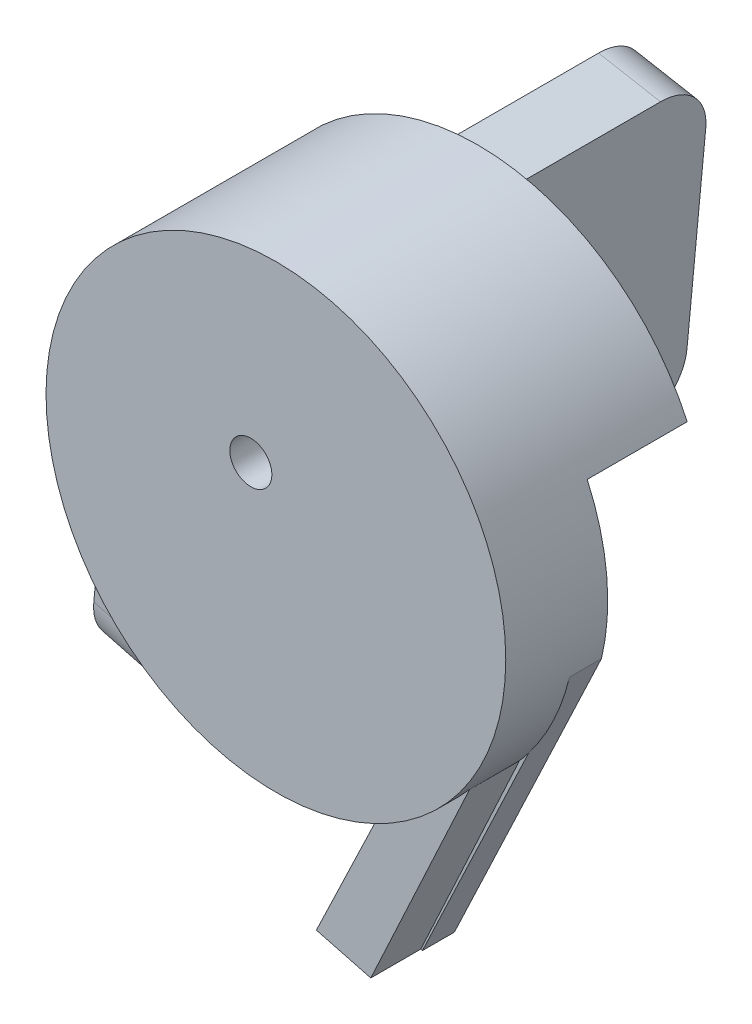
from build123d import *

# Parameters (mm, degrees)
BOSS_EXTRUDE3_DEPTH = 13.2
BOSS_EXTRUDE4_DEPTH = 40
SKETCH3_R           = 23
BOSS_EXTRUDE5_DEPTH = 7
SKETCH4_R           = 2.101716342
CUT_EXTRUDE1_DEPTH  = 10
SKETCH6_W           = 25.714942096
SKETCH6_H           = 53.927163671
CUT_EXTRUDE2_DEPTH  = 10
BOSS_EXTRUDE6_DEPTH = 5
SKETCH11_W          = 0.356169872
SKETCH11_H          = 3.96875
SKETCH11_W_2        = 1.526442308
SKETCH11_H_2        = 0.407051282
CUT_EXTRUDE5_DEPTH  = 5
FILLET5_R           = 5
FILLET6_R           = 5
FILLET7_R           = 5


with BuildPart() as part:
    # Sketch1 → Boss-Extrude3 (new body)
    with BuildSketch(Plane.XY):
        with BuildLine():
            ThreePointArc((-16.733879942, 0.734685024), (4.365374373, 16.171147349), (14.830379862, -7.786034495))
            Line((14.830379862, -7.786034495), (1.98558973, -34.897127547))
            Line((1.98558973, -34.897127547), (7.660402975, -36.381590217))
            Line((7.660402975, -36.381590217), (22.375667903, -5.322545058))
            ThreePointArc((22.375667903, -5.322545058), (3.672252171, 22.704945805), (-22.912677541, 2.002300652))
            Line((-22.912677541, 2.002300652), (-25.690659105, -27.657354808))
            Line((-25.690659105, -27.657354808), (-19.543738844, -29.265314976))
            Line((-19.543738844, -29.265314976), (-16.733879942, 0.734685024))
        make_face()
    extrude(amount=BOSS_EXTRUDE3_DEPTH)

    # Sketch2 → Boss-Extrude4 (add)
    with BuildSketch(Plane(origin=(0, 0, 0), x_dir=(-1, 0, 0), z_dir=(0, 0, -1))):
        Polygon((22.912677541, 2.002300652), (16.720636216, 0.876084213), (19.543738844, -29.265314976), (25.690659105, -27.657354808), align=None)
    extrude(amount=BOSS_EXTRUDE4_DEPTH)

    # Sketch3 → Boss-Extrude5 (add)
    with BuildSketch(Plane.XY.offset(13.2)):
        Circle(SKETCH3_R)
    extrude(amount=BOSS_EXTRUDE5_DEPTH)

    # Sketch4 → Cut-Extrude1 (cut)
    with BuildSketch(Plane.XY.offset(20.2)):
        with Locations((-2.506003926, 4.326655096)):
            Circle(SKETCH4_R)
    extrude(amount=-CUT_EXTRUDE1_DEPTH, mode=Mode.SUBTRACT)

    # Sketch6 → Cut-Extrude2 (cut)
    with BuildSketch(Plane(origin=(0, 0, 0), x_dir=(-1, 0, 0), z_dir=(0, 0, -1))):
        with Locations((-13.331770184, -17.473361846)):
            Rectangle(SKETCH6_W, SKETCH6_H)
    extrude(amount=-CUT_EXTRUDE2_DEPTH, mode=Mode.SUBTRACT)

    # Sketch7 → Boss-Extrude6 (add)
    with BuildSketch(Plane.XY.offset(13.2)):
        with BuildLine():
            Line((8.554145329, -21.350095964), (2.050563603, -34.914123928))
            Line((2.050563603, -34.914123928), (7.494260499, -36.33812935))
            Line((7.494260499, -36.33812935), (17.377955101, -15.066740739))
            ThreePointArc((17.377955101, -15.066740739), (13.34123669, -18.735298332), (8.554145329, -21.350095964))
        make_face()
    extrude(amount=BOSS_EXTRUDE6_DEPTH)

    # Sketch11 → Cut-Extrude5 (cut)
    with BuildSketch(Plane(origin=(-22.899331118, 2.144796313, 0), x_dir=(0, 0, 1), z_dir=(-0.995642368, 0.093253819, 0))):
        with BuildLine():
            Line((-27.490761449, -14.449425234), (-27.796049911, -14.738813255))
            add(Edge.make_bspline(
                [(-27.796049911, -14.738813255), (-27.85129365, -14.68684433), (-27.96046381, -14.584145708), (-28.138445513, -14.450896634), (-28.324141777, -14.336748466), (-28.516583626, -14.243872645), (-28.711005379, -14.169767282), (-28.904826402, -14.117007695), (-29.096058582, -14.083361157), (-29.223248195, -14.079337559), (-29.285921205, -14.077354922)],
                knots=[0, 0, 0, 0, 0.000227393, 0.000449364, 0.000665615, 0.000880379, 0.001089464, 0.001288886, 0.001482323, 0.001670233, 0.001670233, 0.001670233, 0.001670233], degree=3))
            add(Edge.make_bspline(
                [(-29.285921205, -14.077354922), (-29.324378052, -14.077823921), (-29.401192007, -14.078760704), (-29.515290104, -14.090717091), (-29.628191559, -14.107912963), (-29.739683243, -14.132793485), (-29.849981933, -14.164326972), (-29.958704016, -14.203771203), (-30.066052303, -14.249757953), (-30.171015627, -14.302896651), (-30.272774948, -14.36127112), (-30.368883145, -14.42596009), (-30.459952803, -14.494890236), (-30.544272214, -14.569787329), (-30.622326399, -14.649972935), (-30.695973213, -14.733955434), (-30.762622468, -14.824029298), (-30.822824057, -14.918537284), (-30.87652875, -15.015819499), (-30.923936776, -15.114939585), (-30.963734367, -15.215568777), (-30.995222946, -15.317833348), (-31.021201991, -15.420942141), (-31.039478206, -15.525609101), (-31.0497819, -15.631946298), (-31.051564187, -15.703153904), (-31.052460167, -15.738950975)],
                knots=[0, 0, 0, 0, 0.000115322, 0.000230345, 0.000343799, 0.000457798, 0.000572791, 0.000687718, 0.000804532, 0.000922929, 0.001040474, 0.001156236, 0.001270247, 0.001382882, 0.001494196, 0.001605783, 0.001717723, 0.001829979, 0.001941716, 0.002050889, 0.0021594, 0.002266016, 0.002371682, 0.002478206, 0.002584448, 0.002691849, 0.002691849, 0.002691849, 0.002691849], degree=3))
            add(Edge.make_bspline(
                [(-31.052460167, -15.738950975), (-31.051603236, -15.775543777), (-31.049891715, -15.848629457), (-31.038937603, -15.957706665), (-31.018608259, -16.065163862), (-30.991430589, -16.171354156), (-30.957434486, -16.27645941), (-30.915056552, -16.380023953), (-30.864862523, -16.48204395), (-30.806763932, -16.581600176), (-30.743052791, -16.678577176), (-30.671679833, -16.769925919), (-30.595864707, -16.856862836), (-30.512845374, -16.937457676), (-30.425283929, -17.013866201), (-30.330564295, -17.083983266), (-30.230549005, -17.149159466), (-30.12508547, -17.208573376), (-30.015318029, -17.261650912), (-29.902767961, -17.308849437), (-29.787075706, -17.347719757), (-29.668849263, -17.379399571), (-29.548229571, -17.405366873), (-29.424604366, -17.422072453), (-29.298882634, -17.434195092), (-29.214134364, -17.43508145), (-29.171438032, -17.435527998)],
                knots=[0, 0, 0, 0, 0.000109785, 0.00021927, 0.000328423, 0.000437561, 0.000547932, 0.000659544, 0.000772965, 0.000888736, 0.00100516, 0.001120769, 0.001236245, 0.001350932, 0.001467605, 0.001584633, 0.001704151, 0.001825542, 0.001947502, 0.002069752, 0.002191435, 0.00231332, 0.002436812, 0.002561276, 0.002687381, 0.002815419, 0.002815419, 0.002815419, 0.002815419], degree=3))
            add(Edge.make_bspline(
                [(-29.171438032, -17.435527998), (-29.119982227, -17.434452381), (-29.018940395, -17.43234023), (-28.870411125, -17.415897938), (-28.727759429, -17.390218092), (-28.591386145, -17.352610334), (-28.461132881, -17.304640988), (-28.336522135, -17.246815862), (-28.218534986, -17.176917036), (-28.106816744, -17.098025241), (-28.003904579, -17.010128957), (-27.911087849, -16.91528212), (-27.829846982, -16.813945116), (-27.758971117, -16.706714803), (-27.700337197, -16.592703609), (-27.652210099, -16.472470257), (-27.61531967, -16.345960667), (-27.600176082, -16.258544263), (-27.59252427, -16.214374152)],
                knots=[0, 0, 0, 0, 0.000154335, 0.000303061, 0.000447768, 0.000588759, 0.000726848, 0.000863779, 0.001000266, 0.001137694, 0.001273596, 0.001405716, 0.001535217, 0.001662669, 0.001790677, 0.001919117, 0.002050709, 0.002185113, 0.002185113, 0.002185113, 0.002185113], degree=3))
            Line((-27.59252427, -16.214374152), (-28.915440936, -16.214374152))
            Line((-28.915440936, -16.214374152), (-28.915440936, -15.80732287))
            Line((-28.915440936, -15.80732287), (-27.236354398, -15.80732287))
            add(Edge.make_bspline(
                [(-27.236354398, -15.80732287), (-27.238288708, -15.883191183), (-27.242074503, -16.031679177), (-27.26862988, -16.248225824), (-27.311511104, -16.45275444), (-27.370090207, -16.645480423), (-27.445921999, -16.826130658), (-27.538192633, -16.99488856), (-27.648378878, -17.150663903), (-27.772555896, -17.294728398), (-27.91191567, -17.42323563), (-28.062692587, -17.536181649), (-28.225135757, -17.631321222), (-28.399091521, -17.708723937), (-28.583990405, -17.769132842), (-28.780260264, -17.811963112), (-28.987634936, -17.837623874), (-29.129757775, -17.840902492), (-29.202443891, -17.84257928)],
                knots=[0, 0, 0, 0, 0.000227576, 0.000445408, 0.000653412, 0.000853841, 0.001048745, 0.001240174, 0.001429639, 0.00162013, 0.00180972, 0.001997187, 0.002184263, 0.002373234, 0.002567323, 0.002766779, 0.002975044, 0.003193056, 0.003193056, 0.003193056, 0.003193056], degree=3))
            add(Edge.make_bspline(
                [(-29.202443891, -17.84257928), (-29.247245562, -17.841933938), (-29.335608898, -17.840661114), (-29.466113789, -17.831615371), (-29.593020377, -17.817690075), (-29.716310173, -17.79666123), (-29.836436686, -17.770904434), (-29.952799965, -17.737922173), (-30.06584328, -17.699744273), (-30.175741353, -17.656319714), (-30.281496687, -17.606005425), (-30.383580327, -17.550091816), (-30.482556559, -17.488867202), (-30.577751183, -17.421272761), (-30.6696602, -17.347814078), (-30.75769098, -17.26834392), (-30.842336342, -17.18310524), (-30.895359368, -17.122577255), (-30.922076553, -17.092078479)],
                knots=[0, 0, 0, 0, 0.000134396, 0.000265073, 0.000392289, 0.000517239, 0.000640121, 0.000760684, 0.000879852, 0.000997958, 0.001114959, 0.001230945, 0.001346988, 0.001463899, 0.001580984, 0.001699762, 0.001819504, 0.001941119, 0.001941119, 0.001941119, 0.001941119], degree=3))
            add(Edge.make_bspline(
                [(-30.922076553, -17.092078479), (-30.960840958, -17.043693007), (-31.037726319, -16.94772521), (-31.136693514, -16.793964559), (-31.221059391, -16.634758878), (-31.289512189, -16.469664969), (-31.342963412, -16.298837255), (-31.381297288, -16.122494023), (-31.403757339, -15.940408192), (-31.406993047, -15.817189543), (-31.408630039, -15.754851416)],
                knots=[0, 0, 0, 0, 0.000185896, 0.000368706, 0.000547588, 0.000725795, 0.000904073, 0.00108387, 0.001266496, 0.001453496, 0.001453496, 0.001453496, 0.001453496], degree=3))
            add(Edge.make_bspline(
                [(-31.408630039, -15.754851416), (-31.408026519, -15.708171826), (-31.406827149, -15.615405915), (-31.39228393, -15.477682004), (-31.371418036, -15.34240354), (-31.340748608, -15.209681106), (-31.30208588, -15.07942606), (-31.253833266, -14.951577922), (-31.197652893, -14.826061246), (-31.132355053, -14.703739985), (-31.059687854, -14.586237303), (-30.980822872, -14.474026222), (-30.894640218, -14.369150229), (-30.802547303, -14.270281128), (-30.703445358, -14.178661007), (-30.598262797, -14.093441613), (-30.48691856, -14.014508635), (-30.369062356, -13.94310534), (-30.246453286, -13.878966235), (-30.119385248, -13.822735611), (-29.987897033, -13.776263458), (-29.852973733, -13.736832476), (-29.713594067, -13.707673343), (-29.570769485, -13.686526998), (-29.423755518, -13.67205739), (-29.324382521, -13.670893689), (-29.273995874, -13.670303639)],
                knots=[0, 0, 0, 0, 0.00013998, 0.000278182, 0.000415029, 0.000550417, 0.000686496, 0.000822349, 0.000960062, 0.00109877, 0.00123799, 0.00137431, 0.001509903, 0.001644898, 0.00177935, 0.001914441, 0.002050761, 0.002188472, 0.002327512, 0.002465629, 0.002604942, 0.002745598, 0.002887025, 0.003031729, 0.003178637, 0.003329743, 0.003329743, 0.003329743, 0.003329743], degree=3))
            add(Edge.make_bspline(
                [(-29.273995874, -13.670303639), (-29.232904294, -13.670960742), (-29.15142452, -13.672263698), (-29.030178377, -13.68129504), (-28.910806298, -13.69560962), (-28.793131285, -13.715143565), (-28.677554066, -13.741749714), (-28.563745391, -13.773588483), (-28.451540283, -13.810658675), (-28.341290393, -13.854869242), (-28.232254412, -13.905049692), (-28.123826075, -13.961534555), (-28.016375858, -14.025289694), (-27.909717424, -14.096504417), (-27.803178192, -14.173955614), (-27.698443285, -14.259858441), (-27.59298459, -14.350825316), (-27.525173604, -14.416232792), (-27.490761449, -14.449425234)],
                knots=[0, 0, 0, 0, 0.000123269, 0.000244429, 0.000364538, 0.000483868, 0.000602094, 0.000720146, 0.000838308, 0.000956413, 0.001076296, 0.001198266, 0.001323024, 0.001450914, 0.001582897, 0.001717987, 0.001857171, 0.002000577, 0.002000577, 0.002000577, 0.002000577], degree=3))
        make_face()
        with Locations((-26.244166898, -15.75644146)):
            Rectangle(SKETCH11_W, SKETCH11_H)
        Polygon((-23.420248629, -13.77206646), (-21.588517859, -17.74081646), (-21.975693591, -17.74081646), (-22.562419853, -16.468781204), (-24.361554718, -16.468781204), (-24.964976443, -17.74081646), (-25.353742218, -17.74081646), (-23.471130039, -13.77206646), align=None)
        Polygon((-23.449664444, -14.5456229), (-24.168364364, -16.061729922), (-22.750045053, -16.061729922), align=None, mode=Mode.SUBTRACT)
        with BuildLine():
            Line((-20.876178116, -13.77206646), (-20.520008244, -13.77206646))
            Line((-20.520008244, -13.77206646), (-20.520008244, -16.149977367))
            add(Edge.make_bspline(
                [(-20.520008244, -16.149977367), (-20.520061248, -16.183633202), (-20.520161833, -16.247500947), (-20.519489965, -16.338406074), (-20.517608359, -16.419223951), (-20.516422089, -16.490266104), (-20.513783059, -16.551206541), (-20.51163081, -16.60237542), (-20.508863393, -16.643530453), (-20.505537447, -16.667548111), (-20.504107803, -16.677871999)],
                knots=[0, 0, 0, 0, 0.000100968, 0.000191604, 0.000272712, 0.000343486, 0.00040475, 0.000455687, 0.00049715, 0.00052841, 0.00052841, 0.00052841, 0.00052841], degree=3))
            add(Edge.make_bspline(
                [(-20.504107803, -16.677871999), (-20.498236935, -16.715117882), (-20.486826, -16.787510977), (-20.45774484, -16.890594475), (-20.417130352, -16.983498897), (-20.369002973, -17.069123307), (-20.305579387, -17.145084456), (-20.229602164, -17.215061063), (-20.137552373, -17.276261234), (-20.035203293, -17.332221529), (-19.924888783, -17.3771989), (-19.812163508, -17.411209232), (-19.698721915, -17.431936199), (-19.622775728, -17.434336203), (-19.58506233, -17.435527998)],
                knots=[0, 0, 0, 0, 0.000113064, 0.000219757, 0.000320182, 0.000416724, 0.000513328, 0.000615741, 0.000725557, 0.000844018, 0.00096523, 0.001082195, 0.001196825, 0.001309897, 0.001309897, 0.001309897, 0.001309897], degree=3))
            add(Edge.make_bspline(
                [(-19.58506233, -17.435527998), (-19.552684428, -17.434310329), (-19.488115631, -17.431882023), (-19.392177981, -17.416844507), (-19.298742144, -17.389742973), (-19.20734673, -17.35477289), (-19.12167731, -17.308568032), (-19.041686086, -17.255193062), (-18.970289482, -17.192587872), (-18.905136217, -17.123304446), (-18.848400173, -17.045131637), (-18.799220397, -16.959771606), (-18.75893653, -16.865939757), (-18.739043426, -16.799996796), (-18.728823599, -16.766119445)],
                knots=[0, 0, 0, 0, 9.7152e-05, 0.000193743, 0.00029039, 0.000388568, 0.00048673, 0.000581767, 0.000676452, 0.000770956, 0.000866524, 0.000965529, 0.001065954, 0.001172053, 0.001172053, 0.001172053, 0.001172053], degree=3))
            add(Edge.make_bspline(
                [(-18.728823599, -16.766119445), (-18.725421671, -16.752117043), (-18.717840805, -16.720914051), (-18.710757102, -16.66816223), (-18.703379167, -16.605921612), (-18.698259967, -16.533745003), (-18.693269297, -16.451874257), (-18.690283581, -16.359882876), (-18.688903552, -16.258104893), (-18.688492299, -16.187078826), (-18.688277475, -16.149977367)],
                knots=[0, 0, 0, 0, 4.3203e-05, 9.6273e-05, 0.000159486, 0.000231254, 0.00031328, 0.000405558, 0.000507333, 0.000618639, 0.000618639, 0.000618639, 0.000618639], degree=3))
            Line((-18.688277475, -16.149977367), (-18.688277475, -13.77206646))
            Line((-18.688277475, -13.77206646), (-18.332107603, -13.77206646))
            Line((-18.332107603, -13.77206646), (-18.332107603, -16.169057896))
            add(Edge.make_bspline(
                [(-18.332107603, -16.169057896), (-18.332395757, -16.212258737), (-18.332958108, -16.296567803), (-18.337834655, -16.420110862), (-18.345610003, -16.537305761), (-18.356595602, -16.648168252), (-18.371151847, -16.752301629), (-18.387338927, -16.850618643), (-18.407953219, -16.942413555), (-18.43203038, -17.0284021), (-18.459554849, -17.110255316), (-18.495206866, -17.187939191), (-18.535375718, -17.263815341), (-18.583017334, -17.336736143), (-18.636551669, -17.407024466), (-18.697162057, -17.474254043), (-18.762843918, -17.539499211), (-18.834689133, -17.601086349), (-18.91151339, -17.65756583), (-18.993088163, -17.707229374), (-19.078786822, -17.749211512), (-19.168386599, -17.783769034), (-19.26192573, -17.809752552), (-19.359406576, -17.829114559), (-19.461051018, -17.840116272), (-19.530180584, -17.841751317), (-19.56518678, -17.84257928)],
                knots=[0, 0, 0, 0, 0.000129598, 0.000252919, 0.000370851, 0.000481918, 0.000587044, 0.000686247, 0.000780758, 0.000869105, 0.000954087, 0.001039492, 0.001125214, 0.001211437, 0.001300483, 0.00139001, 0.001482769, 0.001578056, 0.001673624, 0.001768522, 0.001864166, 0.001959545, 0.002056192, 0.002155044, 0.002257413, 0.002362431, 0.002362431, 0.002362431, 0.002362431], degree=3))
            add(Edge.make_bspline(
                [(-19.56518678, -17.84257928), (-19.603365137, -17.841689413), (-19.678270938, -17.839943495), (-19.788645353, -17.829939127), (-19.894456987, -17.811095055), (-19.996823383, -17.78710119), (-20.094350875, -17.754008917), (-20.18834612, -17.715344079), (-20.277199267, -17.667858257), (-20.362351779, -17.615024677), (-20.441528065, -17.555578882), (-20.514209942, -17.490786006), (-20.580517403, -17.421683971), (-20.639332799, -17.347524628), (-20.691630588, -17.268884746), (-20.736681812, -17.185541858), (-20.775363794, -17.097528231), (-20.795328384, -17.036349156), (-20.805421155, -17.005421077)],
                knots=[0, 0, 0, 0, 0.000114552, 0.000224751, 0.000332058, 0.000436763, 0.00053984, 0.000640686, 0.000741328, 0.000841696, 0.000941074, 0.001037929, 0.001133524, 0.001228011, 0.001321503, 0.001416488, 0.001511904, 0.001609455, 0.001609455, 0.001609455, 0.001609455], degree=3))
            add(Edge.make_bspline(
                [(-20.805421155, -17.005421077), (-20.811291682, -16.984293069), (-20.824024987, -16.938465948), (-20.837660816, -16.862621447), (-20.849123792, -16.775292032), (-20.859902416, -16.676471724), (-20.866262574, -16.566083928), (-20.871838598, -16.444176497), (-20.876217398, -16.310602023), (-20.876191576, -16.217558063), (-20.876178116, -16.169057896)],
                knots=[0, 0, 0, 0, 6.5757e-05, 0.000142627, 0.000230889, 0.000330012, 0.000440752, 0.000562517, 0.00069614, 0.000841631, 0.000841631, 0.000841631, 0.000841631], degree=3))
            Line((-20.876178116, -16.169057896), (-20.876178116, -13.77206646))
        make_face()
        with Locations((-16.907428116, -16.214374152)):
            Rectangle(SKETCH11_W_2, SKETCH11_H_2)
        with BuildLine():
            Line((-12.17466194, -17.298784208), (-11.564880039, -18.046104922))
            Line((-11.564880039, -18.046104922), (-12.009297357, -18.046104922))
            Line((-12.009297357, -18.046104922), (-12.449739564, -17.507079982))
            add(Edge.make_bspline(
                [(-12.449739564, -17.507079982), (-12.493914125, -17.533924307), (-12.581449515, -17.587118463), (-12.717936684, -17.655682777), (-12.857138096, -17.71273723), (-12.998745753, -17.759874611), (-13.142553396, -17.79760532), (-13.28929026, -17.823792027), (-13.438424142, -17.838998322), (-13.538620794, -17.841381077), (-13.589006141, -17.84257928)],
                knots=[0, 0, 0, 0, 0.000155029, 0.000307203, 0.000457647, 0.000605978, 0.000754649, 0.000903267, 0.001052702, 0.001203858, 0.001203858, 0.001203858, 0.001203858], degree=3))
            add(Edge.make_bspline(
                [(-13.589006141, -17.84257928), (-13.66119242, -17.840840575), (-13.803233529, -17.837419321), (-14.011842501, -17.807551124), (-14.212075712, -17.761422321), (-14.403534053, -17.694678532), (-14.586426086, -17.609426967), (-14.760666841, -17.504323949), (-14.926344878, -17.380825276), (-15.081014538, -17.239738051), (-15.222444253, -17.086254803), (-15.346539965, -16.922264875), (-15.452054849, -16.750489484), (-15.537369919, -16.570072038), (-15.605078829, -16.3825832), (-15.651220615, -16.186463683), (-15.681087656, -15.982880958), (-15.684528412, -15.844265934), (-15.68627427, -15.773931945)],
                knots=[0, 0, 0, 0, 0.000216456, 0.000425922, 0.000630911, 0.000832053, 0.001033007, 0.001235207, 0.001441436, 0.001651929, 0.001862372, 0.002066694, 0.002267946, 0.002466023, 0.00266443, 0.002864779, 0.00306952, 0.003280416, 0.003280416, 0.003280416, 0.003280416], degree=3))
            add(Edge.make_bspline(
                [(-15.68627427, -15.773931945), (-15.685653112, -15.726725043), (-15.684415161, -15.632642907), (-15.670094605, -15.493297632), (-15.648817807, -15.356246341), (-15.618722602, -15.222058564), (-15.579325468, -15.090184284), (-15.532092373, -14.960883537), (-15.47486319, -14.834489499), (-15.410166988, -14.711260858), (-15.338012165, -14.592265645), (-15.259412278, -14.479197478), (-15.174173965, -14.373170651), (-15.082357568, -14.274233676), (-14.984329773, -14.182167851), (-14.88093354, -14.095457129), (-14.769964255, -14.01732724), (-14.65435074, -13.944669577), (-14.533444649, -13.880777223), (-14.409610901, -13.823659501), (-14.281923153, -13.777315667), (-14.152038164, -13.737825106), (-14.019167936, -13.707676316), (-13.883416023, -13.686555491), (-13.744877926, -13.672096806), (-13.651320155, -13.670905011), (-13.604111559, -13.670303639)],
                knots=[0, 0, 0, 0, 0.00014157, 0.000282145, 0.000419778, 0.000557491, 0.000694332, 0.000832421, 0.000970134, 0.001110248, 0.001249731, 0.001387352, 0.001523061, 0.001657514, 0.001791929, 0.001926295, 0.002061967, 0.002198741, 0.002335672, 0.002471936, 0.002607512, 0.00274283, 0.002878992, 0.00301584, 0.003154833, 0.003296402, 0.003296402, 0.003296402, 0.003296402], degree=3))
            add(Edge.make_bspline(
                [(-13.604111559, -13.670303639), (-13.53192501, -13.672033616), (-13.390146009, -13.675431399), (-13.18205383, -13.7053041), (-12.982410497, -13.751618009), (-12.791358132, -13.818021656), (-12.609067075, -13.903487915), (-12.435613909, -14.008569748), (-12.270729715, -14.132076602), (-12.116868253, -14.273173274), (-11.975771633, -14.427034728), (-11.852264585, -14.591918901), (-11.74718346, -14.765372159), (-11.661714579, -14.94766287), (-11.595320801, -15.138716539), (-11.548909755, -15.338610937), (-11.519179691, -15.546989497), (-11.515744445, -15.689027096), (-11.513998629, -15.761211592)],
                knots=[0, 0, 0, 0, 0.000216456, 0.000425134, 0.00062935, 0.000830492, 0.001030725, 0.001232244, 0.001437837, 0.001647742, 0.001857648, 0.00206324, 0.002264759, 0.002464993, 0.002666135, 0.00287035, 0.003079816, 0.003296272, 0.003296272, 0.003296272, 0.003296272], degree=3))
            add(Edge.make_bspline(
                [(-11.513998629, -15.761211592), (-11.515906597, -15.836320034), (-11.51965851, -15.984016533), (-11.551587929, -16.200597713), (-11.602924829, -16.407483759), (-11.675726754, -16.60453912), (-11.76984319, -16.791727977), (-11.883455877, -16.970922238), (-12.017932725, -17.142109198), (-12.12186868, -17.246009207), (-12.17466194, -17.298784208)],
                knots=[0, 0, 0, 0, 0.000225228, 0.000442899, 0.000655195, 0.000863723, 0.001071717, 0.00128257, 0.00149936, 0.001723147, 0.001723147, 0.001723147, 0.001723147], degree=3))
        make_face()
        with BuildLine():
            add(Edge.make_bspline(
                [(-12.413963572, -17.005421077), (-12.370660336, -16.961443956), (-12.28548095, -16.874939009), (-12.174962372, -16.733075472), (-12.079905308, -16.5856112), (-12.003801779, -16.430584568), (-11.943251046, -16.269937831), (-11.90141714, -16.102398087), (-11.875223298, -15.928728057), (-11.871865821, -15.81059611), (-11.8701685, -15.750876306)],
                knots=[0, 0, 0, 0, 0.000185022, 0.000363946, 0.000538396, 0.000710482, 0.000881043, 0.001052462, 0.001227634, 0.001406728, 0.001406728, 0.001406728, 0.001406728], degree=3))
            add(Edge.make_bspline(
                [(-11.8701685, -15.750876306), (-11.870611985, -15.712417494), (-11.871488676, -15.6363912), (-11.883543158, -15.523885622), (-11.900596665, -15.413864877), (-11.925284916, -15.30652554), (-11.957077316, -15.202085087), (-11.996343724, -15.100685296), (-12.042319095, -15.001999045), (-12.095916332, -14.906639367), (-12.155002751, -14.814744474), (-12.220773184, -14.727438199), (-12.292301874, -14.645170717), (-12.368807404, -14.566586298), (-12.451764799, -14.493304857), (-12.540876543, -14.425357806), (-12.635044577, -14.361100845), (-12.734734885, -14.303100644), (-12.837465718, -14.24977851), (-12.942635957, -14.203604841), (-13.049362522, -14.164497398), (-13.15748014, -14.132786284), (-13.266848906, -14.107825599), (-13.377660566, -14.090791174), (-13.489628561, -14.078749105), (-13.56485845, -14.077820046), (-13.602521515, -14.077354922)],
                knots=[0, 0, 0, 0, 0.000115322, 0.000227971, 0.00033907, 0.000449191, 0.000558086, 0.000666308, 0.000775142, 0.000884408, 0.000994227, 0.001102668, 0.001212012, 0.001321078, 0.001431469, 0.001543733, 0.001657073, 0.001773244, 0.001889516, 0.002004143, 0.002117575, 0.002230278, 0.002341949, 0.002453833, 0.002566482, 0.00267942, 0.00267942, 0.00267942, 0.00267942], degree=3))
            add(Edge.make_bspline(
                [(-13.602521515, -14.077354922), (-13.640448888, -14.077823291), (-13.716206211, -14.078758827), (-13.828714769, -14.090724571), (-13.939780742, -14.107844351), (-14.04891564, -14.132680979), (-14.156505948, -14.164453762), (-14.262217715, -14.203797631), (-14.366970265, -14.24883083), (-14.468589884, -14.302118917), (-14.566898775, -14.360617864), (-14.660396751, -14.4242359), (-14.747802489, -14.493607745), (-14.829945116, -14.567616518), (-14.906619467, -14.646833253), (-14.97818756, -14.730731003), (-15.043392535, -14.820283239), (-15.103132558, -14.913887729), (-15.155933624, -15.011646174), (-15.203553486, -15.111794779), (-15.242231392, -15.215437669), (-15.273985132, -15.321745289), (-15.299932744, -15.430453349), (-15.316656987, -15.542192897), (-15.328801891, -15.656266385), (-15.329666886, -15.733352159), (-15.330104398, -15.772341901)],
                knots=[0, 0, 0, 0, 0.000113733, 0.000227173, 0.000339057, 0.000450728, 0.000562668, 0.000675354, 0.000788934, 0.0009045, 0.001019303, 0.001131986, 0.001243484, 0.001353812, 0.001463447, 0.001573998, 0.001684355, 0.001795513, 0.001906867, 0.002017478, 0.002127929, 0.002238345, 0.002350195, 0.002462864, 0.002577096, 0.002694007, 0.002694007, 0.002694007, 0.002694007], degree=3))
            add(Edge.make_bspline(
                [(-15.330104398, -15.772341901), (-15.328614918, -15.829665291), (-15.325684652, -15.942438134), (-15.301393471, -16.108008131), (-15.260666258, -16.266516026), (-15.203687196, -16.418188584), (-15.132157799, -16.563900018), (-15.043205585, -16.702222842), (-14.937210049, -16.832630204), (-14.818181049, -16.956017825), (-14.687247372, -17.067802068), (-14.548444975, -17.166184407), (-14.40295892, -17.249653105), (-14.250332357, -17.317022083), (-14.091703427, -17.371121652), (-13.925819918, -17.407748141), (-13.753766215, -17.432025162), (-13.636527743, -17.434349447), (-13.57708081, -17.435527998)],
                knots=[0, 0, 0, 0, 0.000171909, 0.000338198, 0.00050075, 0.000662006, 0.000823425, 0.00098684, 0.001154211, 0.001326819, 0.00150049, 0.001669897, 0.001836549, 0.002002756, 0.002169692, 0.00233845, 0.002511715, 0.002689944, 0.002689944, 0.002689944, 0.002689944], degree=3))
            add(Edge.make_bspline(
                [(-13.57708081, -17.435527998), (-13.536238513, -17.435083078), (-13.455455333, -17.434203057), (-13.336331595, -17.422205391), (-13.220122938, -17.40531843), (-13.107905482, -17.379635015), (-12.998706129, -17.347704882), (-12.893174867, -17.308864757), (-12.790751892, -17.262819463), (-12.725626894, -17.226392217), (-12.693016307, -17.208151696)],
                knots=[0, 0, 0, 0, 0.000122475, 0.000242246, 0.000358844, 0.000474568, 0.000587271, 0.000699956, 0.000811679, 0.000923732, 0.000923732, 0.000923732, 0.000923732], degree=3))
            Line((-12.693016307, -17.208151696), (-13.586621074, -16.112611332))
            Line((-13.586621074, -16.112611332), (-13.142203757, -16.112611332))
            Line((-13.142203757, -16.112611332), (-12.413963572, -17.005421077))
        make_face(mode=Mode.SUBTRACT)
        with BuildLine():
            Line((-10.699896064, -13.77206646), (-10.343726193, -13.77206646))
            Line((-10.343726193, -13.77206646), (-10.343726193, -16.149977367))
            add(Edge.make_bspline(
                [(-10.343726193, -16.149977367), (-10.343779197, -16.183633202), (-10.343879782, -16.247500947), (-10.343207913, -16.338406074), (-10.341326308, -16.419223951), (-10.340140038, -16.490266104), (-10.337501008, -16.551206541), (-10.335348758, -16.60237542), (-10.332581341, -16.643530453), (-10.329255396, -16.667548111), (-10.327825752, -16.677871999)],
                knots=[0, 0, 0, 0, 0.000100968, 0.000191604, 0.000272712, 0.000343486, 0.00040475, 0.000455687, 0.00049715, 0.00052841, 0.00052841, 0.00052841, 0.00052841], degree=3))
            add(Edge.make_bspline(
                [(-10.327825752, -16.677871999), (-10.321954883, -16.715117882), (-10.310543949, -16.787510977), (-10.281462788, -16.890594475), (-10.240848301, -16.983498897), (-10.192720922, -17.069123307), (-10.129297336, -17.145084456), (-10.053320113, -17.215061063), (-9.961270322, -17.276261234), (-9.858921242, -17.332221529), (-9.748606732, -17.3771989), (-9.635881456, -17.411209232), (-9.522439864, -17.431936199), (-9.446493677, -17.434336203), (-9.408780279, -17.435527998)],
                knots=[0, 0, 0, 0, 0.000113064, 0.000219757, 0.000320182, 0.000416724, 0.000513328, 0.000615741, 0.000725557, 0.000844018, 0.00096523, 0.001082195, 0.001196825, 0.001309897, 0.001309897, 0.001309897, 0.001309897], degree=3))
            add(Edge.make_bspline(
                [(-9.408780279, -17.435527998), (-9.376402377, -17.434310329), (-9.311833579, -17.431882023), (-9.21589593, -17.416844507), (-9.122460093, -17.389742973), (-9.031064679, -17.35477289), (-8.945395259, -17.308568032), (-8.865404035, -17.255193062), (-8.794007431, -17.192587872), (-8.728854165, -17.123304446), (-8.672118122, -17.045131637), (-8.622938345, -16.959771606), (-8.582654479, -16.865939757), (-8.562761375, -16.799996796), (-8.552541547, -16.766119445)],
                knots=[0, 0, 0, 0, 9.7152e-05, 0.000193743, 0.00029039, 0.000388568, 0.00048673, 0.000581767, 0.000676452, 0.000770956, 0.000866524, 0.000965529, 0.001065954, 0.001172053, 0.001172053, 0.001172053, 0.001172053], degree=3))
            add(Edge.make_bspline(
                [(-8.552541547, -16.766119445), (-8.549139619, -16.752117043), (-8.541558753, -16.720914051), (-8.534475051, -16.66816223), (-8.527097115, -16.605921612), (-8.521977916, -16.533745003), (-8.516987246, -16.451874257), (-8.51400153, -16.359882876), (-8.512621501, -16.258104893), (-8.512210248, -16.187078826), (-8.511995423, -16.149977367)],
                knots=[0, 0, 0, 0, 4.3203e-05, 9.6273e-05, 0.000159486, 0.000231254, 0.00031328, 0.000405558, 0.000507333, 0.000618639, 0.000618639, 0.000618639, 0.000618639], degree=3))
            Line((-8.511995423, -16.149977367), (-8.511995423, -13.77206646))
            Line((-8.511995423, -13.77206646), (-8.155825552, -13.77206646))
            Line((-8.155825552, -13.77206646), (-8.155825552, -16.169057896))
            add(Edge.make_bspline(
                [(-8.155825552, -16.169057896), (-8.156113706, -16.212258737), (-8.156676057, -16.296567803), (-8.161552603, -16.420110862), (-8.169327951, -16.537305761), (-8.180313551, -16.648168252), (-8.194869796, -16.752301629), (-8.211056876, -16.850618643), (-8.231671168, -16.942413555), (-8.255748328, -17.0284021), (-8.283272798, -17.110255316), (-8.318924814, -17.187939191), (-8.359093667, -17.263815341), (-8.406735282, -17.336736143), (-8.460269618, -17.407024466), (-8.520880006, -17.474254043), (-8.586561867, -17.539499211), (-8.658407082, -17.601086349), (-8.735231338, -17.65756583), (-8.816806112, -17.707229374), (-8.90250477, -17.749211512), (-8.992104547, -17.783769034), (-9.085643679, -17.809752552), (-9.183124525, -17.829114559), (-9.284768967, -17.840116272), (-9.353898532, -17.841751317), (-9.388904728, -17.84257928)],
                knots=[0, 0, 0, 0, 0.000129598, 0.000252919, 0.000370851, 0.000481918, 0.000587044, 0.000686247, 0.000780758, 0.000869105, 0.000954087, 0.001039492, 0.001125214, 0.001211437, 0.001300483, 0.00139001, 0.001482769, 0.001578056, 0.001673624, 0.001768522, 0.001864166, 0.001959545, 0.002056192, 0.002155044, 0.002257413, 0.002362431, 0.002362431, 0.002362431, 0.002362431], degree=3))
            add(Edge.make_bspline(
                [(-9.388904728, -17.84257928), (-9.427083086, -17.841689413), (-9.501988886, -17.839943495), (-9.612363302, -17.829939127), (-9.718174935, -17.811095055), (-9.820541332, -17.78710119), (-9.918068824, -17.754008917), (-10.012064069, -17.715344079), (-10.100917216, -17.667858257), (-10.186069728, -17.615024677), (-10.265246014, -17.555578882), (-10.337927891, -17.490786006), (-10.404235351, -17.421683971), (-10.463050748, -17.347524628), (-10.515348537, -17.268884746), (-10.560399761, -17.185541858), (-10.599081743, -17.097528231), (-10.619046332, -17.036349156), (-10.629139103, -17.005421077)],
                knots=[0, 0, 0, 0, 0.000114552, 0.000224751, 0.000332058, 0.000436763, 0.00053984, 0.000640686, 0.000741328, 0.000841696, 0.000941074, 0.001037929, 0.001133524, 0.001228011, 0.001321503, 0.001416488, 0.001511904, 0.001609455, 0.001609455, 0.001609455, 0.001609455], degree=3))
            add(Edge.make_bspline(
                [(-10.629139103, -17.005421077), (-10.635009631, -16.984293069), (-10.647742936, -16.938465948), (-10.661378765, -16.862621447), (-10.672841741, -16.775292032), (-10.683620365, -16.676471724), (-10.689980523, -16.566083928), (-10.695556547, -16.444176497), (-10.699935347, -16.310602023), (-10.699909525, -16.217558063), (-10.699896064, -16.169057896)],
                knots=[0, 0, 0, 0, 6.5757e-05, 0.000142627, 0.000230889, 0.000330012, 0.000440752, 0.000562517, 0.00069614, 0.000841631, 0.000841631, 0.000841631, 0.000841631], degree=3))
            Line((-10.699896064, -16.169057896), (-10.699896064, -13.77206646))
        make_face()
        Polygon((-5.509992218, -13.77206646), (-3.678261449, -17.74081646), (-4.06543718, -17.74081646), (-4.652163442, -16.468781204), (-6.451298308, -16.468781204), (-7.054720033, -17.74081646), (-7.443485808, -17.74081646), (-5.560873629, -13.77206646), align=None)
        Polygon((-5.539408034, -14.5456229), (-6.258107953, -16.061729922), (-4.839788643, -16.061729922), align=None, mode=Mode.SUBTRACT)
        Polygon((-2.965921705, -17.74081646), (-2.965921705, -13.77206646), (-2.891189634, -13.77206646), (-0.269206962, -16.895708036), (-0.269206962, -13.77206646), (0.08696291, -13.77206646), (0.08696291, -17.74081646), (0.005870662, -17.74081646), (-2.609751834, -14.624330082), (-2.609751834, -17.74081646), align=None)
        with BuildLine():
            Line((4.818934064, -14.449425234), (4.513645602, -14.738813255))
            add(Edge.make_bspline(
                [(4.513645602, -14.738813255), (4.458401863, -14.68684433), (4.349231703, -14.584145708), (4.171249999, -14.450896634), (3.985553736, -14.336748466), (3.793111887, -14.243872645), (3.598690134, -14.169767282), (3.404869111, -14.117007695), (3.213636931, -14.083361157), (3.086447318, -14.079337559), (3.023774308, -14.077354922)],
                knots=[0, 0, 0, 0, 0.000227393, 0.000449364, 0.000665615, 0.000880379, 0.001089464, 0.001288886, 0.001482323, 0.001670233, 0.001670233, 0.001670233, 0.001670233], degree=3))
            add(Edge.make_bspline(
                [(3.023774308, -14.077354922), (2.985317461, -14.077823921), (2.908503506, -14.078760704), (2.794405409, -14.090717091), (2.681503954, -14.107912963), (2.57001227, -14.132793485), (2.459713579, -14.164326972), (2.350991496, -14.203771203), (2.24364321, -14.249757953), (2.138679886, -14.302896651), (2.036920565, -14.36127112), (1.940812368, -14.42596009), (1.84974271, -14.494890236), (1.765423299, -14.569787329), (1.687369114, -14.649972935), (1.6137223, -14.733955434), (1.547073044, -14.824029298), (1.486871456, -14.918537284), (1.433166763, -15.015819499), (1.385758737, -15.114939585), (1.345961146, -15.215568777), (1.314472567, -15.317833348), (1.288493522, -15.420942141), (1.270217306, -15.525609101), (1.259913613, -15.631946298), (1.258131326, -15.703153904), (1.257235346, -15.738950975)],
                knots=[0, 0, 0, 0, 0.000115322, 0.000230345, 0.000343799, 0.000457798, 0.000572791, 0.000687718, 0.000804532, 0.000922929, 0.001040474, 0.001156236, 0.001270247, 0.001382882, 0.001494196, 0.001605783, 0.001717723, 0.001829979, 0.001941716, 0.002050889, 0.0021594, 0.002266016, 0.002371682, 0.002478206, 0.002584448, 0.002691849, 0.002691849, 0.002691849, 0.002691849], degree=3))
            add(Edge.make_bspline(
                [(1.257235346, -15.738950975), (1.258092276, -15.775543777), (1.259803797, -15.848629457), (1.27075791, -15.957706665), (1.291087254, -16.065163862), (1.318264924, -16.171354156), (1.352261027, -16.27645941), (1.394638961, -16.380023953), (1.44483299, -16.48204395), (1.50293158, -16.581600176), (1.566642722, -16.678577176), (1.63801568, -16.769925919), (1.713830806, -16.856862836), (1.796850139, -16.937457676), (1.884411584, -17.013866201), (1.979131218, -17.083983266), (2.079146508, -17.149159466), (2.184610043, -17.208573376), (2.294377484, -17.261650912), (2.406927552, -17.308849437), (2.522619807, -17.347719757), (2.64084625, -17.379399571), (2.761465942, -17.405366873), (2.885091147, -17.422072453), (3.010812879, -17.434195092), (3.095561149, -17.43508145), (3.138257481, -17.435527998)],
                knots=[0, 0, 0, 0, 0.000109785, 0.00021927, 0.000328423, 0.000437561, 0.000547932, 0.000659544, 0.000772965, 0.000888736, 0.00100516, 0.001120769, 0.001236245, 0.001350932, 0.001467605, 0.001584633, 0.001704151, 0.001825542, 0.001947502, 0.002069752, 0.002191435, 0.00231332, 0.002436812, 0.002561276, 0.002687381, 0.002815419, 0.002815419, 0.002815419, 0.002815419], degree=3))
            add(Edge.make_bspline(
                [(3.138257481, -17.435527998), (3.189713286, -17.434452381), (3.290755118, -17.43234023), (3.439284387, -17.415897938), (3.581936084, -17.390218092), (3.718309368, -17.352610334), (3.848562632, -17.304640988), (3.973173378, -17.246815862), (4.091160527, -17.176917036), (4.202878768, -17.098025241), (4.305790934, -17.010128957), (4.398607664, -16.91528212), (4.479848531, -16.813945116), (4.550724396, -16.706714803), (4.609358316, -16.592703609), (4.657485414, -16.472470257), (4.694375843, -16.345960667), (4.709519431, -16.258544263), (4.717171243, -16.214374152)],
                knots=[0, 0, 0, 0, 0.000154335, 0.000303061, 0.000447768, 0.000588759, 0.000726848, 0.000863779, 0.001000266, 0.001137694, 0.001273596, 0.001405716, 0.001535217, 0.001662669, 0.001790677, 0.001919117, 0.002050709, 0.002185113, 0.002185113, 0.002185113, 0.002185113], degree=3))
            Line((4.717171243, -16.214374152), (3.394254577, -16.214374152))
            Line((3.394254577, -16.214374152), (3.394254577, -15.80732287))
            Line((3.394254577, -15.80732287), (5.073341115, -15.80732287))
            add(Edge.make_bspline(
                [(5.073341115, -15.80732287), (5.071406805, -15.883191183), (5.06762101, -16.031679177), (5.041065633, -16.248225824), (4.998184409, -16.45275444), (4.939605305, -16.645480423), (4.863773514, -16.826130658), (4.771502879, -16.99488856), (4.661316635, -17.150663903), (4.537139616, -17.294728398), (4.397779843, -17.42323563), (4.247002926, -17.536181649), (4.084559756, -17.631321222), (3.910603992, -17.708723937), (3.725705108, -17.769132842), (3.529435249, -17.811963112), (3.322060577, -17.837623874), (3.179937738, -17.840902492), (3.107251622, -17.84257928)],
                knots=[0, 0, 0, 0, 0.000227576, 0.000445408, 0.000653412, 0.000853841, 0.001048745, 0.001240174, 0.001429639, 0.00162013, 0.00180972, 0.001997187, 0.002184263, 0.002373234, 0.002567323, 0.002766779, 0.002975044, 0.003193056, 0.003193056, 0.003193056, 0.003193056], degree=3))
            add(Edge.make_bspline(
                [(3.107251622, -17.84257928), (3.06244995, -17.841933938), (2.974086615, -17.840661114), (2.843581724, -17.831615371), (2.716675136, -17.817690075), (2.59338534, -17.79666123), (2.473258827, -17.770904434), (2.356895548, -17.737922173), (2.243852233, -17.699744273), (2.13395416, -17.656319714), (2.028198826, -17.606005425), (1.926115186, -17.550091816), (1.827138954, -17.488867202), (1.73194433, -17.421272761), (1.640035312, -17.347814078), (1.552004533, -17.26834392), (1.467359171, -17.18310524), (1.414336145, -17.122577255), (1.38761896, -17.092078479)],
                knots=[0, 0, 0, 0, 0.000134396, 0.000265073, 0.000392289, 0.000517239, 0.000640121, 0.000760684, 0.000879852, 0.000997958, 0.001114959, 0.001230945, 0.001346988, 0.001463899, 0.001580984, 0.001699762, 0.001819504, 0.001941119, 0.001941119, 0.001941119, 0.001941119], degree=3))
            add(Edge.make_bspline(
                [(1.38761896, -17.092078479), (1.348854555, -17.043693007), (1.271969194, -16.94772521), (1.173001998, -16.793964559), (1.088636122, -16.634758878), (1.020183324, -16.469664969), (0.966732101, -16.298837255), (0.928398225, -16.122494023), (0.905938174, -15.940408192), (0.902702466, -15.817189543), (0.901065474, -15.754851416)],
                knots=[0, 0, 0, 0, 0.000185896, 0.000368706, 0.000547588, 0.000725795, 0.000904073, 0.00108387, 0.001266496, 0.001453496, 0.001453496, 0.001453496, 0.001453496], degree=3))
            add(Edge.make_bspline(
                [(0.901065474, -15.754851416), (0.901668994, -15.708171826), (0.902868364, -15.615405915), (0.917411583, -15.477682004), (0.938277477, -15.34240354), (0.968946905, -15.209681106), (1.007609633, -15.07942606), (1.055862247, -14.951577922), (1.11204262, -14.826061246), (1.177340459, -14.703739985), (1.250007659, -14.586237303), (1.328872641, -14.474026222), (1.415055295, -14.369150229), (1.50714821, -14.270281128), (1.606250155, -14.178661007), (1.711432715, -14.093441613), (1.822776952, -14.014508635), (1.940633156, -13.94310534), (2.063242227, -13.878966235), (2.190310265, -13.822735611), (2.32179848, -13.776263458), (2.45672178, -13.736832476), (2.596101446, -13.707673343), (2.738926028, -13.686526998), (2.885939994, -13.67205739), (2.985312992, -13.670893689), (3.035699639, -13.670303639)],
                knots=[0, 0, 0, 0, 0.00013998, 0.000278182, 0.000415029, 0.000550417, 0.000686496, 0.000822349, 0.000960062, 0.00109877, 0.00123799, 0.00137431, 0.001509903, 0.001644898, 0.00177935, 0.001914441, 0.002050761, 0.002188472, 0.002327512, 0.002465629, 0.002604942, 0.002745598, 0.002887025, 0.003031729, 0.003178637, 0.003329743, 0.003329743, 0.003329743, 0.003329743], degree=3))
            add(Edge.make_bspline(
                [(3.035699639, -13.670303639), (3.076791219, -13.670960742), (3.158270993, -13.672263698), (3.279517136, -13.68129504), (3.398889215, -13.69560962), (3.516564228, -13.715143565), (3.632141447, -13.741749714), (3.745950122, -13.773588483), (3.85815523, -13.810658675), (3.96840512, -13.854869242), (4.077441101, -13.905049692), (4.185869438, -13.961534555), (4.293319655, -14.025289694), (4.399978089, -14.096504417), (4.506517321, -14.173955614), (4.611252228, -14.259858441), (4.716710923, -14.350825316), (4.784521909, -14.416232792), (4.818934064, -14.449425234)],
                knots=[0, 0, 0, 0, 0.000123269, 0.000244429, 0.000364538, 0.000483868, 0.000602094, 0.000720146, 0.000838308, 0.000956413, 0.001076296, 0.001198266, 0.001323024, 0.001450914, 0.001582897, 0.001717987, 0.001857171, 0.002000577, 0.002000577, 0.002000577, 0.002000577], degree=3))
        make_face()
    extrude(amount=-CUT_EXTRUDE5_DEPTH, mode=Mode.SUBTRACT)

    # Fillet5
    fillet5_edges = [part.edges().sort_by_distance(p)[0] for p in [
        (-22.617198974, -28.461334892, -40),
    ]]
    fillet(fillet5_edges, radius=FILLET5_R)

    # Fillet6
    fillet6_edges = [part.edges().sort_by_distance(p)[0] for p in [
        (-19.816656879, 1.439192432, -40),
    ]]
    fillet(fillet6_edges, radius=FILLET6_R)

    # Fillet7
    fillet7_edges = [part.edges().sort_by_distance(p)[0] for p in [
        (-22.617198974, -28.461334892, 13.2),
    ]]
    fillet(fillet7_edges, radius=FILLET7_R)


solid = part.part
